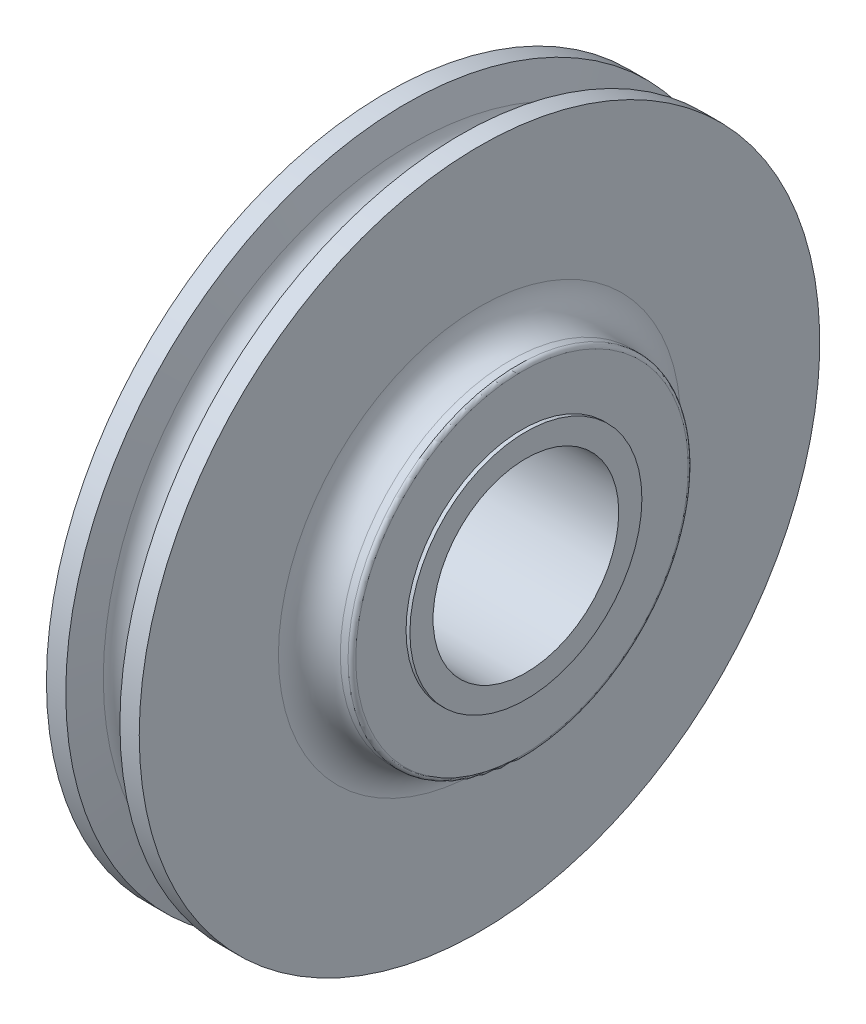
from build123d import *

# Parameters (mm, degrees)
SKETCH2_R          = 38.1127
CUT_EXTRUDE1_DEPTH = 77.2


with BuildPart() as part:
    # Sketch1 → Revolve1 (revolve)
    with BuildSketch(Plane.XY, mode=Mode.PRIVATE) as revolve1_sk:
        with BuildLine():
            Line((-38.1, 47.625), (-38.1, 0))
            Line((-38.1, 0), (38.1, 0))
            Line((38.1, 0), (38.1, 47.625))
            Line((38.1, 47.625), (36.5125, 47.625))
            Line((36.5125, 47.625), (36.5125, 68.2625))
            ThreePointArc((36.5125, 68.2625), (36.047532015, 69.385032015), (34.925, 69.85))
            Line((34.925, 69.85), (31.75, 69.85))
            ThreePointArc((31.75, 69.85), (22.769743879, 73.569743879), (19.05, 82.55))
            Line((19.05, 82.55), (19.05, 139.7))
            Line((19.05, 139.7), (11.1125, 139.7))
            Line((11.1125, 139.7), (8.542828829, 126.8589166))
            ThreePointArc((8.542828829, 126.8589166), (0, 119.85625), (-8.542828829, 126.8589166))
            Line((-8.542828829, 126.8589166), (-11.1125, 139.7))
            Line((-11.1125, 139.7), (-19.05, 139.7))
            Line((-19.05, 139.7), (-19.05, 82.55))
            ThreePointArc((-19.05, 82.55), (-22.769743879, 73.569743879), (-31.75, 69.85))
            Line((-31.75, 69.85), (-34.925, 69.85))
            ThreePointArc((-34.925, 69.85), (-36.047532015, 69.385032015), (-36.5125, 68.2625))
            Line((-36.5125, 68.2625), (-36.5125, 47.625))
            Line((-36.5125, 47.625), (-38.1, 47.625))
        make_face()
    revolve(revolve1_sk.sketch.rotate(Axis((-38.1, 0, 0), (1, 0, 0)), 90), axis=Axis((-38.1, 0, 0), (1, 0, 0)))  # turned: the seam where the file's is

    # Sketch2 → Cut-Extrude1 (cut, through all)
    with BuildSketch(Plane(origin=(38.1, 0, 0), x_dir=(0, 0, -1), z_dir=(1, 0, 0))):
        Circle(SKETCH2_R)
    extrude(amount=-CUT_EXTRUDE1_DEPTH, mode=Mode.SUBTRACT)


solid = part.part
